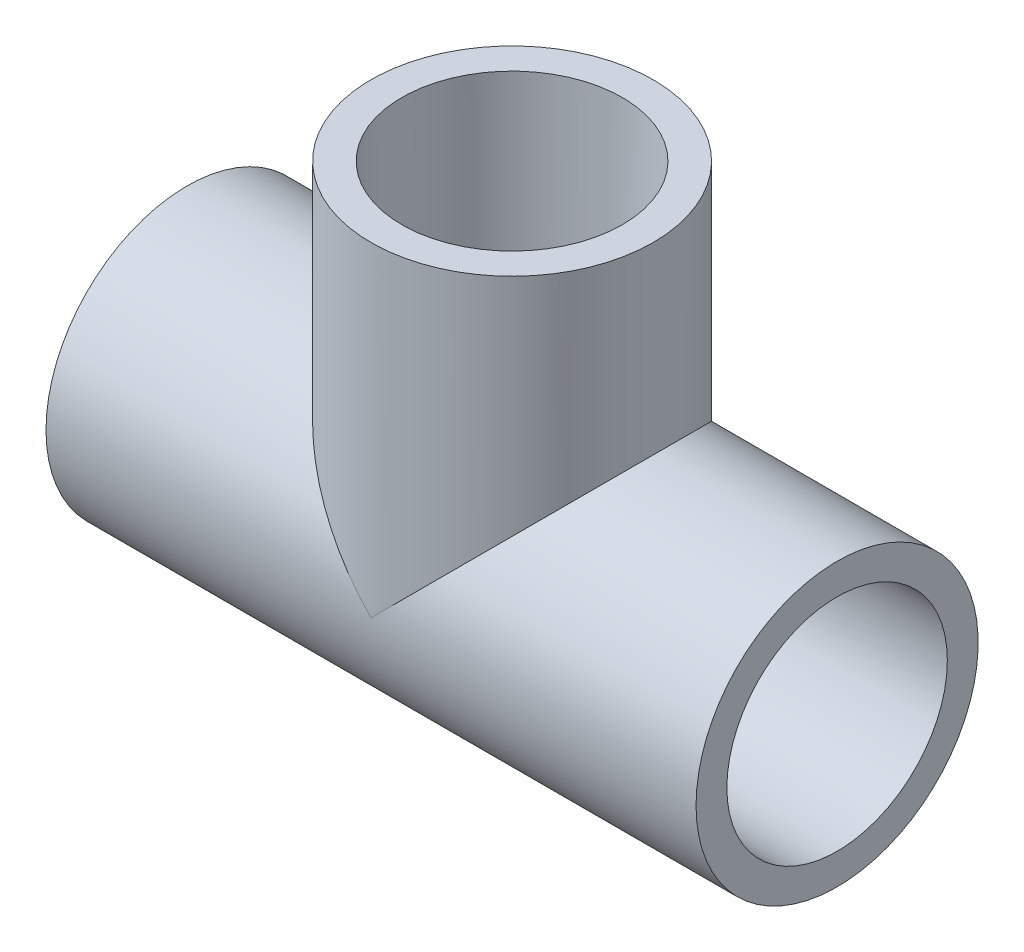
from build123d import *

# Parameters (mm, degrees)
SKETCH4_R                    = 13.7795
BOSS_EXTRUDE1_DEPTH          = 25.4
SKETCH5_R                    = 13.7795
BOSS_EXTRUDE2_DEPTH          = 12.7
F_3_8_0_375_DIAMETER_HOLE1_D = 9.525


with BuildPart() as part:
    # Sketch1 → Revolve1 (revolve)
    with BuildSketch(Plane.XY):
        Polygon((-31.75, -13.7795), (-12.7, -13.7795), (-12.7, -10.6172), (-31.75, -10.7696), align=None)
        Polygon((31.75, -10.7696), (12.7, -10.6172), (12.7, -13.7795), (31.75, -13.7795), align=None)
    revolve(axis=Axis((-31.75, 0, 0), (1, 0, 0)))



with BuildPart() as body_2:
    # Sketch2 → Revolve2 (revolve)
    with BuildSketch(Plane.XY):
        Polygon((10.7696, 31.75), (10.6172, 12.7), (13.7795, 12.7), (13.7795, 31.75), align=None)
    revolve(axis=Axis((0, 0, 0), (0, 1, 0)))


with BuildPart() as part_1:
    add(part.part)

    add(body_2.part)  # Boss-Extrude1 merges body 2
    # Sketch4 → Boss-Extrude1 (add)
    with BuildSketch(Plane(origin=(-12.7, 0, 0), x_dir=(0, 0, -1), z_dir=(1, 0, 0))):
        Circle(SKETCH4_R)
    extrude(amount=BOSS_EXTRUDE1_DEPTH)

    # Sketch5 → Boss-Extrude2 (add)
    with BuildSketch(Plane.XZ.offset(-12.7)):
        Circle(SKETCH5_R)
    extrude(amount=BOSS_EXTRUDE2_DEPTH)

    # Sketch6 → Cut-Revolve1 (revolve, cut)
    with BuildSketch(Plane.XY):
        Polygon((-31.75, -10.7696), (-12.7, -10.6172), (-12.7, -7.8994), (12.7, -7.8994), (12.7, -10.6172), (31.75, -10.7696), (31.75, 0), (-31.75, 0), align=None)
    revolve(axis=Axis((31.75, 0, 0), (-1, 0, 0)), mode=Mode.SUBTRACT)

    # Sketch7 → Cut-Revolve2 (revolve, cut)
    with BuildSketch(Plane.XY):
        Polygon((10.7696, 31.75), (10.6172, 12.7), (7.8994, 12.7), (7.8994, 0), (0, 0), (0, 31.75), align=None)
    revolve(axis=Axis((0, 0, 0), (0, 1, 0)), mode=Mode.SUBTRACT)

    # 3/8 (0.375) Diameter Hole1 (through all)
    with Locations(Plane(origin=(0, 31.75, 0), x_dir=(-1, 0, 0), z_dir=(0, 1, 0))):
        with Locations((0, 0)):
            Hole(F_3_8_0_375_DIAMETER_HOLE1_D / 2)


solid = part_1.part
